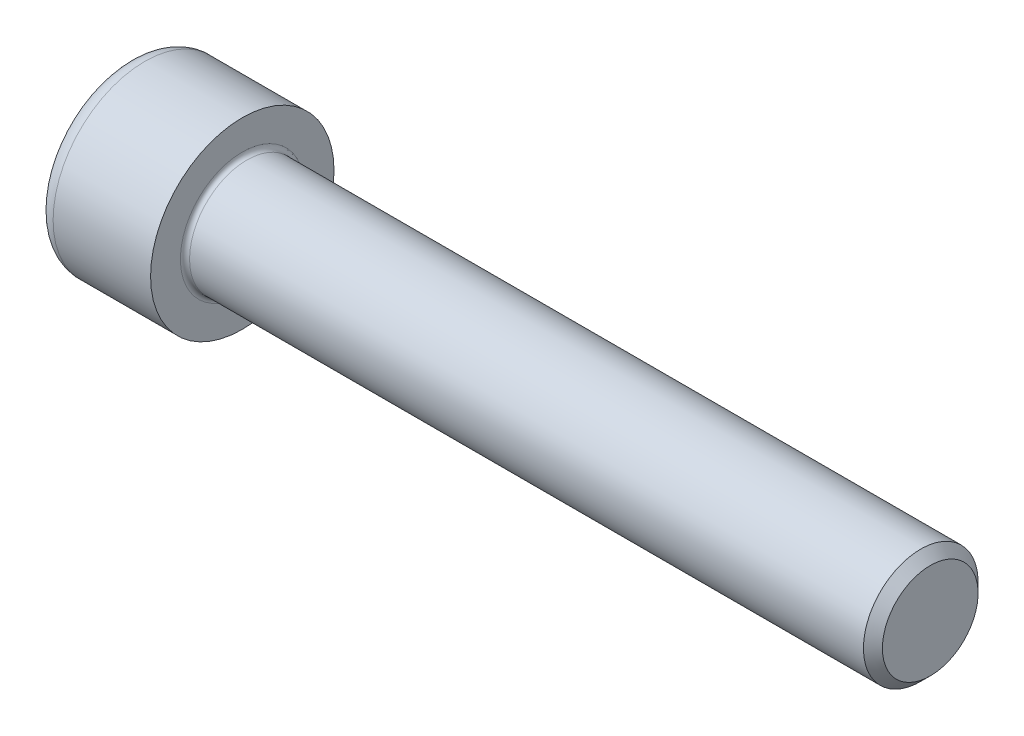
from build123d import *

# Parameters (mm, degrees)
FILLET1_R   = 0.4
FILLET2_R   = 1.5
HEX_2_DEPTH = 5


with BuildPart() as part:
    # BodySke → Base-Revolve (revolve)
    with BuildSketch(Plane.XY):
        Polygon((0, 0), (0, 8), (10, 8), (10, 5), (69.172, 5), (70, 4.172), (70, 0), align=None)
    revolve(axis=Axis((-31.75, 0, 0), (1, 0, 0)))

    # Fillet1
    fillet1_edges = [part.edges().sort_by_distance(p)[0] for p in [
        (10, -5, 0),
    ]]
    fillet(fillet1_edges, radius=FILLET1_R)

    # Fillet2
    fillet2_edges = [part.edges().sort_by_distance(p)[0] for p in [
        (0, -8, 0),
    ]]
    fillet(fillet2_edges, radius=FILLET2_R)

    # Sketch2 → Hex-PreBroach (revolve, cut)
    with BuildSketch(Plane.XY):
        Polygon((0, 4.0575), (5, 4.0575), (7.342598717, 0), (0, 0), align=None)
    revolve(axis=Axis((0, 0, 0), (1, 0, 0)), mode=Mode.SUBTRACT)

    # Sketch3 → Hex 2 (cut)
    with BuildSketch(Plane(origin=(0, 0, 0), x_dir=(0, 0.5, 0.866025404), z_dir=(-1, 0, 0))):
        Polygon((2.342598717, 4.0575), (-2.342598717, 4.0575), (-4.685197434, 0), (-2.342598717, -4.0575), (2.342598717, -4.0575), (4.685197434, 0), align=None)
    extrude(amount=-HEX_2_DEPTH, mode=Mode.SUBTRACT)


solid = part.part
